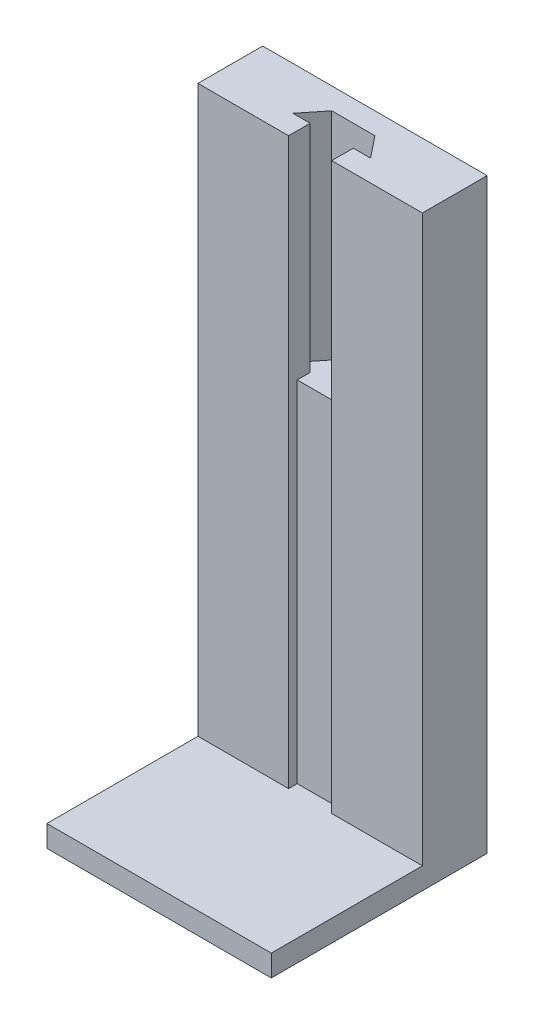
from build123d import *

# Parameters (mm, degrees)
SKETCH1_W           = 52
SKETCH1_H           = 50
BOSS_EXTRUDE1_DEPTH = 5
SKETCH2_W           = 52
SKETCH2_H           = 15
BOSS_EXTRUDE2_DEPTH = 131
CUT_EXTRUDE1_DEPTH  = 50
SKETCH4_W           = 10
SKETCH4_H           = 2
CUT_EXTRUDE2_DEPTH  = 81


with BuildPart() as part:
    # Sketch1 → Boss-Extrude1 (new body)
    with BuildSketch(Plane(origin=(0, 0, 0), x_dir=(1, 0, 0), z_dir=(0, 1, 0))):
        Rectangle(SKETCH1_W, SKETCH1_H)
    extrude(amount=BOSS_EXTRUDE1_DEPTH)

    # Sketch2 → Boss-Extrude2 (add)
    with BuildSketch(Plane(origin=(0, 5, 0), x_dir=(1, 0, 0), z_dir=(0, 1, 0))):
        with Locations((0, 17.5)):
            Rectangle(SKETCH2_W, SKETCH2_H)
    extrude(amount=BOSS_EXTRUDE2_DEPTH)

    # Sketch3 → Cut-Extrude1 (cut)
    with BuildSketch(Plane(origin=(0, 136, 0), x_dir=(1, 0, 0), z_dir=(0, 1, 0))):
        Polygon((-5, 10), (5, 10), (5, 15), (9, 15), (5, 20), (-5, 20), (-9, 15), (-5, 15), align=None)
    extrude(amount=-CUT_EXTRUDE1_DEPTH, mode=Mode.SUBTRACT)

    # Sketch4 → Cut-Extrude2 (cut)
    with BuildSketch(Plane(origin=(0, 86, 0), x_dir=(1, 0, 0), z_dir=(0, 1, 0))):
        with Locations((0, 11)):
            Rectangle(SKETCH4_W, SKETCH4_H)
    extrude(amount=-CUT_EXTRUDE2_DEPTH, mode=Mode.SUBTRACT)


solid = part.part
